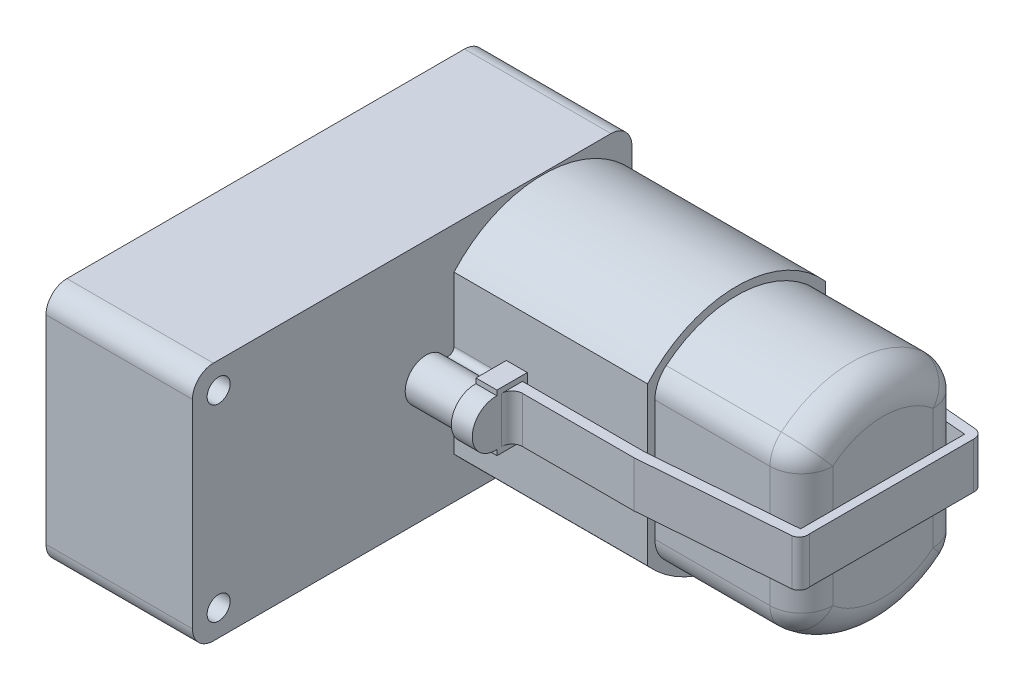
from build123d import *

# Parameters (mm, degrees)
SKETCH1_W                = 14
SKETCH1_H                = 42
MAIN_BODY_DEPTH          = 23
FILLET1_R                = 2
MOTOR_HOLDER_DEPTH       = 18.5
BOSS_EXTRUDE3_DEPTH      = 5
SKETCH4_R                = 1.1
NUT_HOLES_DEPTH          = 15
SKETCH5_W                = 2
SKETCH5_H                = 4
BOSS_EXTRUDE4_DEPTH      = 5
BOSS_EXTRUDE5_DEPTH      = 4
CUT_EXTRUDE2_DEPTH       = 2
BOSS_EXTRUDE6_DEPTH      = 14
BOSS_EXTRUDE7_DEPTH      = 2
FILLET2_R                = 3
BOSS_EXTRUDE8_DEPTH      = 2.2
BOSS_EXTRUDE8_DEPTH_BACK = 2.2
FILLET3_R                = 1
SKETCH12_R               = 3.5
SKETCH12_R_2             = 3.070336519
BOSS_EXTRUDE9_DEPTH      = 1
SKETCH14_R               = 3
BOSS_EXTRUDE10_DEPTH     = 1
SKETCH15_R               = 1
SHAFT_DEPTH              = 7
SKETCH16_R               = 2
BOSS_EXTRUDE12_DEPTH     = 1.5


with BuildPart() as part:
    # Sketch1 → Main Body (new body)
    with BuildSketch(Plane(origin=(0, 0, 0), x_dir=(1, 0, 0), z_dir=(0, 1, 0))):
        with Locations((-14.72963025, -0.456790856)):
            Rectangle(SKETCH1_W, SKETCH1_H)
    extrude(amount=MAIN_BODY_DEPTH)

    # Fillet1
    fillet1_edges = [part.edges().sort_by_distance(p)[0] for p in [
        (-14.72963025, 23, -20.543209144),
        (-14.72963025, 0, -20.543209144),
        (-14.72963025, 0, 21.456790856),
        (-14.72963025, 23, 21.456790856),
    ]]
    fillet(fillet1_edges, radius=FILLET1_R)

    # Sketch2 → Motor Holder (add)
    with BuildSketch(Plane(origin=(-7.72963025, 0, 0), x_dir=(0, 0, -1), z_dir=(1, 0, 0))):
        with BuildLine():
            Line((3.543209144, 19.033283793), (3.543209144, 3.966716207))
            ThreePointArc((3.543209144, 3.966716207), (12.043209144, 0.142167253), (20.543209144, 3.966716207))
            Line((20.543209144, 3.966716207), (20.543209144, 19.033283793))
            ThreePointArc((20.543209144, 19.033283793), (12.043209144, 22.857832747), (3.543209144, 19.033283793))
        make_face()
    extrude(amount=MOTOR_HOLDER_DEPTH)

    # Sketch3 → Boss-Extrude3 (add)
    with BuildSketch(Plane(origin=(-7.72963025, 0, 0), x_dir=(0, 0, -1), z_dir=(1, 0, 0))):
        with BuildLine():
            Line((3.543209144, 12.866872794), (3.543209144, 10.327683852))
            ThreePointArc((3.543209144, 10.327683852), (3.130583543, 10.726570697), (2.605351044, 10.495266949))
            ThreePointArc((2.605351044, 10.495266949), (-1.12344994, 11.454900344), (2.558290761, 12.581682682))
            ThreePointArc((2.558290761, 12.581682682), (3.155784465, 12.361535772), (3.543209144, 12.866872794))
        make_face()
    extrude(amount=BOSS_EXTRUDE3_DEPTH)

    # Sketch4 → Nut Holes (cut)
    with BuildSketch(Plane(origin=(-7.72963025, 0, 0), x_dir=(0, 0, -1), z_dir=(1, 0, 0))):
        with Locations((-18.956790856, 20.5)):
            Circle(SKETCH4_R)
        with Locations((-18.956790856, 2.5)):
            Circle(SKETCH4_R)
    extrude(amount=-NUT_HOLES_DEPTH, mode=Mode.SUBTRACT)

    # Sketch5 → Boss-Extrude4 (add)
    with BuildSketch(Plane(origin=(0, 0, -20.543209144), x_dir=(-1, 0, 0), z_dir=(0, 0, -1))):
        with Locations((7.72963025, 11.5)):
            Rectangle(SKETCH5_W, SKETCH5_H)
    extrude(amount=BOSS_EXTRUDE4_DEPTH)

    # Sketch6 → Boss-Extrude5 (add)
    with BuildSketch(Plane(origin=(-6.72963025, 0, 0), x_dir=(0, 0, -1), z_dir=(1, 0, 0))):
        with BuildLine():
            ThreePointArc((21.679339079, 10.774749435), (23.912167048, 9.534327071), (25.543209144, 11.5))
            ThreePointArc((25.543209144, 11.5), (23.912167048, 13.465672929), (21.679339079, 12.225250565))
            ThreePointArc((21.679339079, 12.225250565), (21.665841795, 12.183376686), (21.649262587, 12.142624651))
            ThreePointArc((21.649262587, 12.142624651), (21.543692429, 11.456035136), (21.679339079, 10.774749435))
        make_face()
        with BuildLine():
            ThreePointArc((20.543209144, 10.774749435), (21.111274111, 11.147288257), (21.679339079, 10.774749435))
            ThreePointArc((21.679339079, 10.774749435), (21.543692429, 11.456035136), (21.649262587, 12.142624651))
            ThreePointArc((21.649262587, 12.142624651), (21.067309248, 11.796717861), (20.543209144, 12.225250565))
            Line((20.543209144, 12.225250565), (20.543209144, 10.774749435))
        make_face()
    extrude(amount=BOSS_EXTRUDE5_DEPTH)

    # Sketch7 → Cut-Extrude2 (cut)
    with BuildSketch(Plane(origin=(-6.72963025, 0, 0), x_dir=(0, 0, -1), z_dir=(1, 0, 0))):
        with BuildLine():
            Line((23.543209144, 13.5), (23.543209144, 13.967200788))
            Line((23.543209144, 13.967200788), (25.760178749, 13.967200788))
            Line((25.760178749, 13.967200788), (25.760178749, 8.970470958))
            Line((25.760178749, 8.970470958), (23.543209144, 8.970470958))
            Line((23.543209144, 8.970470958), (23.543209144, 9.5))
            ThreePointArc((23.543209144, 9.5), (25.543209144, 11.5), (23.543209144, 13.5))
        make_face()
    extrude(amount=-CUT_EXTRUDE2_DEPTH, mode=Mode.SUBTRACT)

    # Sketch8 → Boss-Extrude6 (add)
    with BuildSketch(Plane(origin=(10.77036975, 0, 0), x_dir=(0, 0, -1), z_dir=(1, 0, 0))):
        with BuildLine():
            Line((4.243209144, 17.35646316), (4.243209144, 5.822511997))
            ThreePointArc((4.243209144, 5.822511997), (4.526819665, 4.549237399), (5.324027945, 3.516705516))
            ThreePointArc((5.324027945, 3.516705516), (12.043209144, 1.086287771), (18.762390342, 3.516705516))
            ThreePointArc((18.762390342, 3.516705516), (19.559598622, 4.549237399), (19.843209144, 5.822511997))
            Line((19.843209144, 5.822511997), (19.843209144, 17.35646316))
            ThreePointArc((19.843209144, 17.35646316), (19.559598622, 18.629737758), (18.762390342, 19.66226964))
            ThreePointArc((18.762390342, 19.66226964), (12.043209144, 22.092687386), (5.324027945, 19.66226964))
            ThreePointArc((5.324027945, 19.66226964), (4.526819665, 18.629737758), (4.243209144, 17.35646316))
        make_face()
    extrude(amount=BOSS_EXTRUDE6_DEPTH)

    # Sketch9 → Boss-Extrude7 (add)
    with BuildSketch(Plane(origin=(-2.72963025, 0, 0), x_dir=(0, 0, -1), z_dir=(1, 0, 0))):
        with BuildLine():
            Line((20.534219475, 8.784213792), (23.432322776, 8.784213792))
            Line((23.432322776, 8.784213792), (23.432322776, 9.263820028))
            ThreePointArc((23.432322776, 9.263820028), (25.790969288, 11.48725138), (23.432322776, 13.710682731))
            Line((23.432322776, 13.710682731), (23.432322776, 14.220655847))
            Line((23.432322776, 14.220655847), (20.534219475, 14.220655847))
            Line((20.534219475, 14.220655847), (20.534219475, 8.784213792))
        make_face()
        with BuildLine():
            Line((3.543209144, 8.784213792), (0.645105842, 8.784213792))
            Line((0.645105842, 8.784213792), (0.645105842, 9.294186907))
            ThreePointArc((0.645105842, 9.294186907), (-1.71354067, 11.517618258), (0.645105842, 13.74104961))
            Line((0.645105842, 13.74104961), (0.645105842, 14.220655847))
            Line((0.645105842, 14.220655847), (3.543209144, 14.220655847))
            Line((3.543209144, 14.220655847), (3.543209144, 8.784213792))
        make_face()
    extrude(amount=BOSS_EXTRUDE7_DEPTH)

    # Fillet2
    fillet2_edges = [part.edges().sort_by_distance(p)[0] for p in [
        (24.77036975, 18.629737758, -4.526819665),
        (24.77036975, 11.589487578, -4.243209144),
        (24.77036975, 4.549237399, -4.526819665),
        (24.77036975, 1.086287771, -12.043209144),
        (24.77036975, 4.549237399, -19.559598622),
        (24.77036975, 11.589487578, -19.843209144),
        (24.77036975, 18.629737758, -19.559598622),
        (24.77036975, 22.092687386, -12.043209144),
    ]]
    fillet(fillet2_edges, radius=FILLET2_R)

    # Sketch10 → Boss-Extrude8 (add, two sides)
    with BuildSketch(Plane(origin=(0, 11.5176, 0), x_dir=(1, 0, 0), z_dir=(0, 1, 0))) as boss_extrude8_sk:
        with BuildLine():
            Line((-0.72963025, 21.98776596), (10.910253109, 21.98776596))
            Line((10.910253109, 21.98776596), (24.77036975, 20.809448862))
            ThreePointArc((24.77036975, 20.809448862), (25.391050954, 20.50205534), (25.604727399, 19.843209144))
            Line((25.604727399, 19.843209144), (25.604727399, 4.166099851))
            ThreePointArc((25.604727399, 4.166099851), (25.476560723, 3.537376336), (24.938530753, 3.187742664))
            Line((24.938530753, 3.187742664), (10.910253109, 2.094157493))
            Line((10.910253109, 2.094157493), (-0.72963025, 2.094157493))
            Line((-0.72963025, 2.094157493), (-0.72963025, 3.0856238))
            Line((-0.72963025, 3.0856238), (10.910253109, 3.0856238))
            Line((10.910253109, 3.0856238), (24.77036975, 4.166099851))
            Line((24.77036975, 4.166099851), (24.77036975, 19.843209144))
            Line((24.77036975, 19.843209144), (10.910253109, 21.021526241))
            Line((10.910253109, 21.021526241), (-0.72963025, 21.021526241))
            Line((-0.72963025, 21.021526241), (-0.72963025, 21.98776596))
        make_face()
    extrude(amount=BOSS_EXTRUDE8_DEPTH)
    extrude(boss_extrude8_sk.sketch, amount=-BOSS_EXTRUDE8_DEPTH_BACK)

    # Fillet3
    fillet3_edges = [part.edges().sort_by_distance(p)[0] for p in [
        (-0.72963025, 11.5176, -21.98776596),
        (-0.72963025, 11.5176, -2.094157493),
    ]]
    fillet(fillet3_edges, radius=FILLET3_R)

    # Sketch12 → Boss-Extrude9 (add)
    with BuildSketch(Plane.ZY.offset(21.72963025)):
        with Locations((10.456790856, 11.5)):
            Circle(SKETCH12_R)
        with Locations((10.456790856, 11.5)):
            Circle(SKETCH12_R_2, mode=Mode.SUBTRACT)
    extrude(amount=BOSS_EXTRUDE9_DEPTH)

    # Sketch14 → Boss-Extrude10 (add)
    with BuildSketch(Plane.ZY.offset(21.72963025)):
        with Locations((10.456790856, 11.5)):
            Circle(SKETCH14_R)
    extrude(amount=BOSS_EXTRUDE10_DEPTH)

    # Sketch15 → Shaft (add)
    with BuildSketch(Plane.ZY.offset(22.72963025)):
        with BuildLine():
            Line((8.848293419, 8.967661951), (8.848293419, 14.032338049))
            ThreePointArc((8.848293419, 14.032338049), (10.456790856, 14.5), (12.065288294, 14.032338049))
            Line((12.065288294, 14.032338049), (12.065288294, 8.967661951))
            ThreePointArc((12.065288294, 8.967661951), (10.456790856, 8.5), (8.848293419, 8.967661951))
        make_face()
        with Locations((10.456790856, 11.5)):
            Circle(SKETCH15_R, mode=Mode.SUBTRACT)
    extrude(amount=SHAFT_DEPTH)

    # Sketch16 → Boss-Extrude12 (add)
    with BuildSketch(Plane.ZY.offset(21.72963025)):
        with Locations((-0.543209144, 11.5)):
            Circle(SKETCH16_R)
    extrude(amount=BOSS_EXTRUDE12_DEPTH)


solid = part.part
